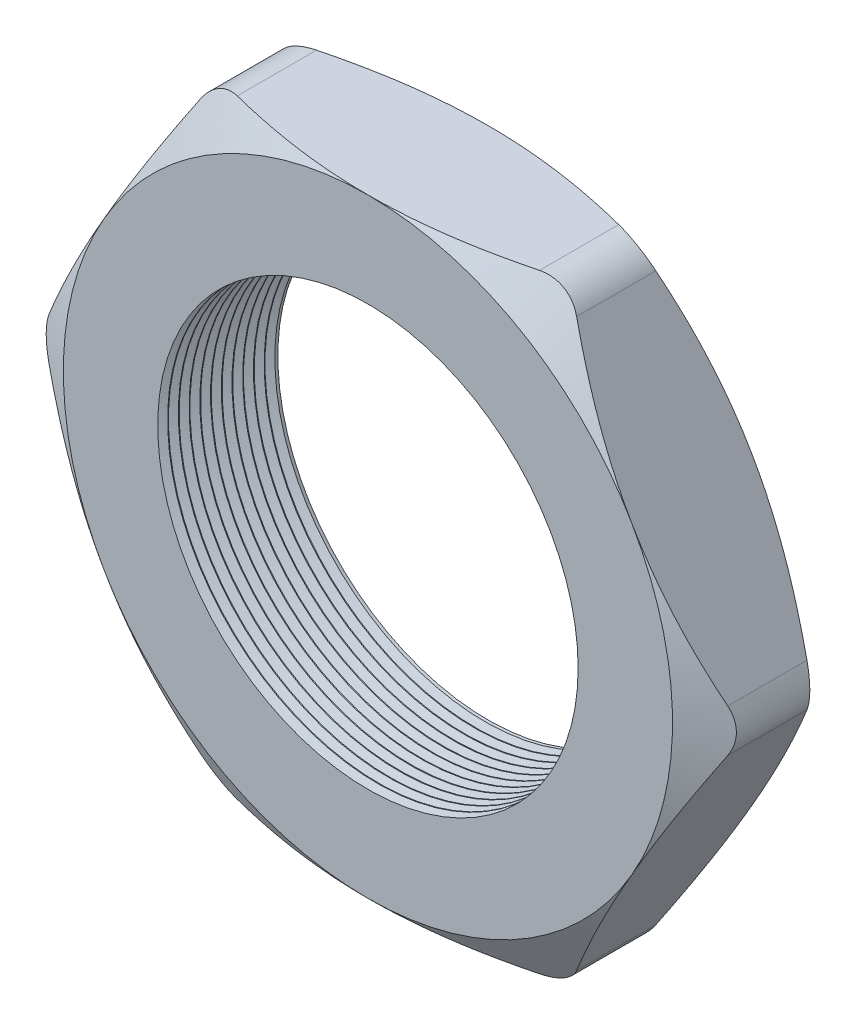
from build123d import *

# Parameters (mm, degrees)
SKETCH1_R          = 12.446
EXTRUDE1_DEPTH     = 7.112
SKETCH2_OUTSIDE_W  = 82.86
SKETCH2_OUTSIDE_H  = 77.28
SKETCH2_OUTSIDE_R  = 18.034
CUT_EXTRUDE1_DEPTH = 8.112
CUT_EXTRUDE1_DRAFT = -60
SKETCH3_OUTSIDE_W  = 82.86
SKETCH3_OUTSIDE_H  = 77.28
SKETCH3_OUTSIDE_R  = 18.034
CUT_EXTRUDE2_DEPTH = 8.112
CUT_EXTRUDE2_DRAFT = -60
FILLET1_R          = 2.54
LPATTERN1_COUNT    = 11
LPATTERN1_PITCH    = 0.635


with BuildPart() as part:
    # Sketch1 → Extrude1 (new body)
    with BuildSketch(Plane.XY):
        Polygon((-20.823869509, 0), (-10.411934755, -18.034), (10.411934755, -18.034), (20.823869509, 0), (10.411934755, 18.034), (-10.411934755, 18.034), align=None)
        Circle(SKETCH1_R, mode=Mode.SUBTRACT)
    extrude(amount=EXTRUDE1_DEPTH)


with BuildPart() as cut_extrude1_tool:
    # Sketch2 outside → Cut-Extrude1 (with draft: the straight prism first)
    with BuildSketch(Plane.XY.offset(7.112)):
        Rectangle(SKETCH2_OUTSIDE_W, SKETCH2_OUTSIDE_H)
        Circle(SKETCH2_OUTSIDE_R, mode=Mode.SUBTRACT)
    extrude(amount=-CUT_EXTRUDE1_DEPTH)
    # Cut-Extrude1: the draft: its side faces are tilted about the plane it starts from
    cut_extrude1_sides = [cut_extrude1_tool.faces().sort_by_distance(p)[0] for p in [
        (0, -38.64, 3.056),
        (41.43, 0, 3.056),
        (0, 38.64, 3.056),
        (-41.43, 0, 3.056),
        (-18.034, 0, 3.056),
    ]]
    draft(cut_extrude1_sides, Plane.XY.offset(7.112), CUT_EXTRUDE1_DRAFT)


with BuildPart() as part_1:
    add(part.part)

    # Cut-Extrude1: cut by cut_extrude1_tool
    add(cut_extrude1_tool.part, mode=Mode.SUBTRACT)


with BuildPart() as cut_extrude2_tool:
    # Sketch3 outside → Cut-Extrude2 (with draft: the straight prism first)
    with BuildSketch(Plane(origin=(0, 0, 0), x_dir=(-1, 0, 0), z_dir=(0, 0, -1))):
        Rectangle(SKETCH3_OUTSIDE_W, SKETCH3_OUTSIDE_H)
        Circle(SKETCH3_OUTSIDE_R, mode=Mode.SUBTRACT)
    extrude(amount=-CUT_EXTRUDE2_DEPTH)
    # Cut-Extrude2: the draft: its side faces are tilted about the plane it starts from
    cut_extrude2_sides = [cut_extrude2_tool.faces().sort_by_distance(p)[0] for p in [
        (0, -38.64, 4.056),
        (-41.43, 0, 4.056),
        (0, 38.64, 4.056),
        (41.43, 0, 4.056),
        (18.034, 0, 4.056),
    ]]
    draft(cut_extrude2_sides, Plane(origin=(0, 0, 0), x_dir=(-1, 0, 0), z_dir=(0, 0, -1)), CUT_EXTRUDE2_DRAFT)


with BuildPart() as part_2:
    add(part_1.part)

    # Cut-Extrude2: cut by cut_extrude2_tool
    add(cut_extrude2_tool.part, mode=Mode.SUBTRACT)

    # Fillet1
    fillet1_edges = [part_2.edges().sort_by_distance(p)[0] for p in [
        (20.823869509, 0, 3.556),
        (10.411934755, -18.034, 3.556),
        (-10.411934755, -18.034, 3.556),
        (-20.823869509, 0, 3.556),
        (-10.411934755, 18.034, 3.556),
        (10.411934755, 18.034, 3.556),
    ]]
    fillet(fillet1_edges, radius=FILLET1_R)

    # Sketch4 → Cut-Revolve1 (revolve, cut)
    with BuildSketch(Plane(origin=(0, 0, 0), x_dir=(1, 0, 0), z_dir=(0, 1, 0)), mode=Mode.PRIVATE) as cut_revolve1_sk:
        Polygon((-12.446, -7.112), (-12.446, -6.525412127), (-12.954, -6.818706063), align=None)
    cut_revolve1 = revolve(cut_revolve1_sk.sketch.rotate(Axis((0, 0, 0), (0, 0, 1)), 180), axis=Axis((0, 0, 0), (0, 0, 1)), mode=Mode.SUBTRACT)  # turned: the seam where the file's is

    # LPattern1: Cut-Revolve1 ×11
    with Locations(*[(0, 0, -i * LPATTERN1_PITCH) for i in range(1, LPATTERN1_COUNT)]):
        add(cut_revolve1, mode=Mode.SUBTRACT)


solid = part_2.part
